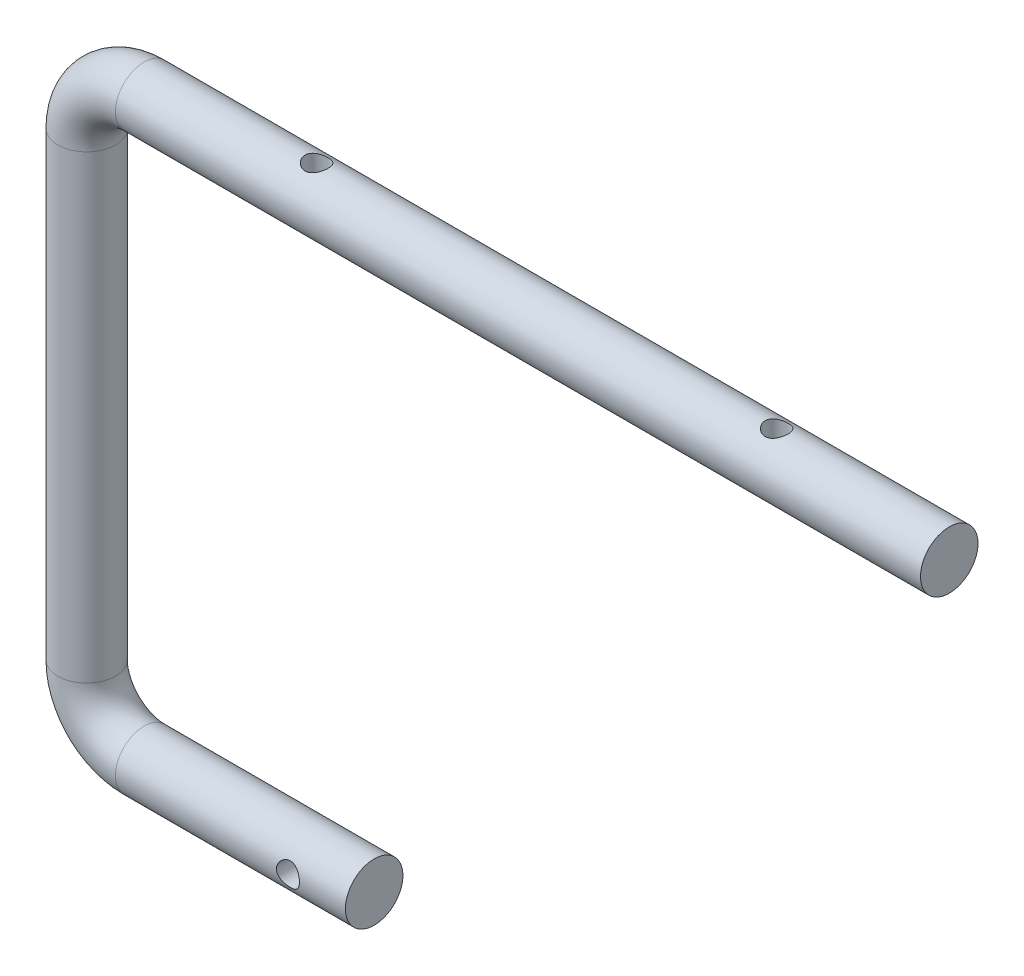
from build123d import *

# Parameters (mm, degrees)
SKETCH_3_R               = 5
CUT_EXTRUDE_1_DEPTH      = 10
CUT_EXTRUDE_1_DEPTH_BACK = 10
SKETCH_4_R               = 2
SKETCH_6_R               = 2
CUT_EXTRUDE_3_DEPTH      = 129


with BuildPart() as part:
    # 扫描1: sweep along a path in 草图1
    with BuildLine(Plane.XY) as sweep_1_path:
        Line((0, 0), (-40, 0))
        ThreePointArc((-40, 0), (-47.071067812, 2.928932188), (-50, 10))
        Line((-50, 10), (-50, 90))
        ThreePointArc((-50, 90), (-47.071067812, 97.071067812), (-40, 100))
        Line((-40, 100), (100, 100))
    # 草图3 → 扫描1 (sweep)
    with BuildSketch(Plane(origin=(0, 0, 0), x_dir=(0, 0, -1), z_dir=(1, 0, 0))):
        Circle(SKETCH_3_R)
    sweep(path=sweep_1_path.line)

    # 草图4 → 切除-拉伸1 (cut, two sides: drawn at the far end of the back side and taken through both)
    with BuildSketch(Plane.XY.offset(-CUT_EXTRUDE_1_DEPTH_BACK)):
        with Locations((-10, 0)):
            Circle(SKETCH_4_R)
    extrude(amount=CUT_EXTRUDE_1_DEPTH + CUT_EXTRUDE_1_DEPTH_BACK, mode=Mode.SUBTRACT)

    # 草图6 → 切除-拉伸3 (cut)
    with BuildSketch(Plane(origin=(0, 70, 0), x_dir=(1, 0, 0), z_dir=(0, 1, 0))):
        with Locations((70, 0)):
            Circle(SKETCH_6_R)
        with Locations((-10, 0)):
            Circle(SKETCH_6_R)
    extrude(amount=CUT_EXTRUDE_3_DEPTH, mode=Mode.SUBTRACT)


solid = part.part
